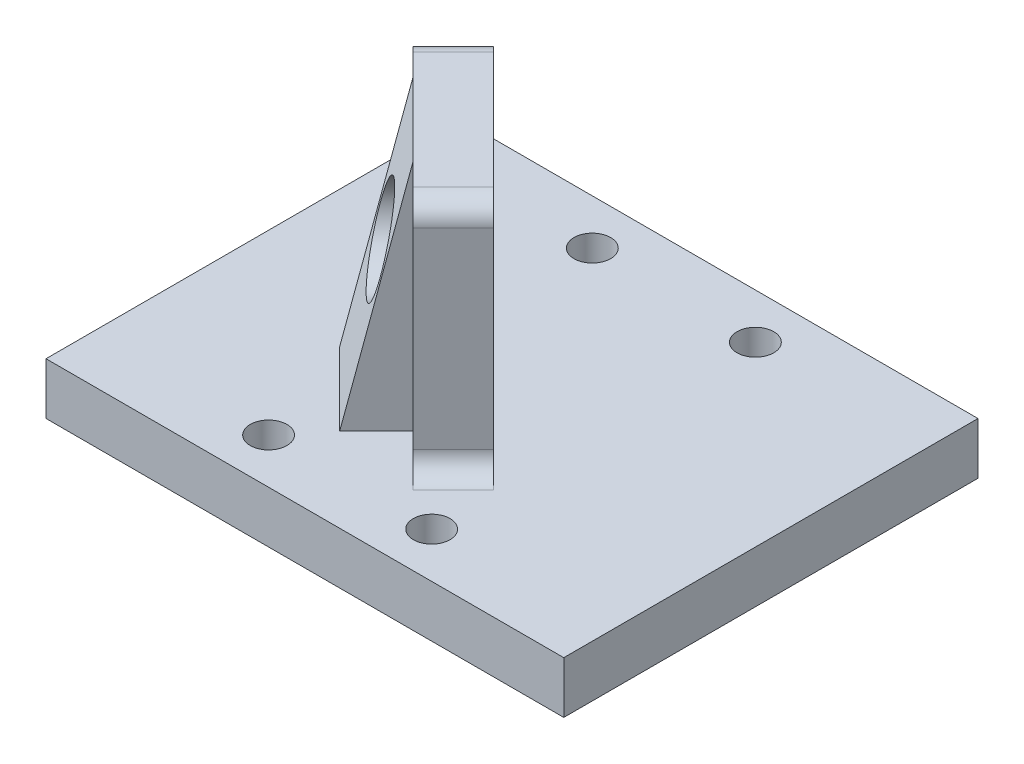
from build123d import *

# Parameters (mm, degrees)
SKETCH1_W           = 63.5
SKETCH1_H           = 50.8
BOSS_EXTRUDE1_DEPTH = 6.35
BOSS_EXTRUDE2_DEPTH = 28.575
SKETCH4_R           = 2.25
CUT_EXTRUDE2_DEPTH  = 7.35
FILLET1_R           = 2.54
SKETCH5_R           = 2.413
CUT_EXTRUDE3_DEPTH  = 39.823652545
BOSS_EXTRUDE3_DEPTH = 6.35
SKETCH7_R           = 5.588
CUT_EXTRUDE4_DEPTH  = 32.823641145


with BuildPart() as part:
    # Sketch1 → Boss-Extrude1 (new body)
    with BuildSketch(Plane(origin=(0, 0, 0), x_dir=(1, 0, 0), z_dir=(0, 1, 0))):
        Rectangle(SKETCH1_W, SKETCH1_H)
    extrude(amount=BOSS_EXTRUDE1_DEPTH)

    # Sketch2 → Boss-Extrude2 (add)
    with BuildSketch(Plane(origin=(0, 6.35, 0), x_dir=(1, 0, 0), z_dir=(0, 1, 0))):
        Polygon((2.907968577, -15.052543666), (-15.052543666, 2.907968577), (-10.102788136, 7.857724106), (7.857724106, -10.102788136), align=None)
    extrude(amount=BOSS_EXTRUDE2_DEPTH)

    # Sketch4 → Cut-Extrude2 (cut, through all)
    with BuildSketch(Plane(origin=(0, 6.35, 0), x_dir=(1, 0, 0), z_dir=(0, 1, 0))):
        with Locations((10, -19.85)):
            Circle(SKETCH4_R)
        with Locations((10, 19.85)):
            Circle(SKETCH4_R)
        with Locations((-10, 19.85)):
            Circle(SKETCH4_R)
        with Locations((-10, -19.85)):
            Circle(SKETCH4_R)
    extrude(amount=-CUT_EXTRUDE2_DEPTH, mode=Mode.SUBTRACT)

    # Fillet1
    fillet1_edges = [part.edges().sort_by_distance(p)[0] for p in [
        (5.382846341, 6.35, 12.577665901),
        (-12.577665901, 6.35, -5.382846341),
        (5.382846341, 34.925, 12.577665901),
        (-12.577665901, 34.925, -5.382846341),
    ]]
    fillet(fillet1_edges, radius=FILLET1_R)

    # Sketch5 → Cut-Extrude3 (cut, through all)
    with BuildSketch(Plane(origin=(-1.122532015, 0, 1.122532015), x_dir=(-0.707106781, 0, -0.707106781), z_dir=(0.707106781, 0, -0.707106781))):
        with Locations((0, 22.225)):
            Circle(SKETCH5_R)
    extrude(amount=-CUT_EXTRUDE3_DEPTH, mode=Mode.SUBTRACT)

    # Sketch6 → Boss-Extrude3 (add, symmetric)
    with BuildSketch(Plane(origin=(0, 0, 0), x_dir=(-0.707106781, 0, 0.707106781), z_dir=(-0.707106781, 0, -0.707106781))):
        Polygon((8.5875114, 34.925), (14.9375114, 6.35), (8.5875114, 6.35), align=None)
    extrude(amount=BOSS_EXTRUDE3_DEPTH, both=True)

    # Sketch7 → Cut-Extrude4 (cut, through all)
    with BuildSketch(Plane(origin=(-6.072287544, 0, 6.072287544), x_dir=(0.707106781, 0, 0.707106781), z_dir=(-0.707106781, 0, 0.707106781))):
        with Locations((0, 22.225)):
            Circle(SKETCH7_R)
    extrude(amount=CUT_EXTRUDE4_DEPTH, mode=Mode.SUBTRACT)


solid = part.part
